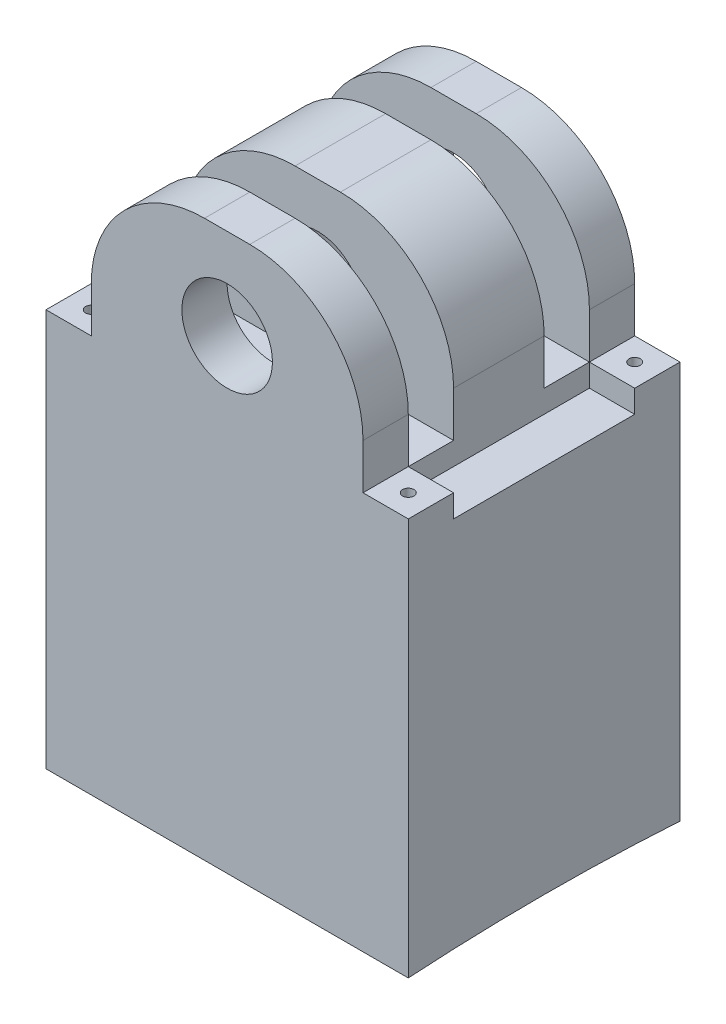
from build123d import *

# Parameters (mm, degrees)
SKETCH1_R                   = 25.4
BOSS_EXTRUDE1_DEPTH         = 152.4
SKETCH3_W                   = 25.4
SKETCH3_H                   = 88.9
CUT_EXTRUDE1_DEPTH          = 102.6
CUT_EXTRUDE1_DEPTH_BACK     = 102.6
F_1_4_0_25_DIAMETER_HOLE1_D = 6.35
SKETCH4_W                   = 25.4
SKETCH4_H                   = 101.6
CUT_EXTRUDE2_DEPTH          = 13.7
SKETCH7_W                   = 203.2
SKETCH7_H                   = 210.309489201
BOSS_EXTRUDE2_DEPTH         = 152.4
CUT_EXTRUDE3_DEPTH          = 204.2


with BuildPart() as part:
    # Sketch1 → Boss-Extrude1 (new body)
    with BuildSketch(Plane.XY):
        with BuildLine():
            Line((-101.6, -50.8), (101.6, -50.8))
            Line((101.6, -50.8), (101.6, -38.1))
            Line((101.6, -38.1), (76.2, -38.1))
            Line((76.2, -38.1), (76.2, -12.7))
            ThreePointArc((76.2, -12.7), (57.601280605, 32.201280605), (12.7, 50.8))
            Line((12.7, 50.8), (-12.7, 50.8))
            ThreePointArc((-12.7, 50.8), (-57.601280605, 32.201280605), (-76.2, -12.7))
            Line((-76.2, -12.7), (-76.2, -38.1))
            Line((-76.2, -38.1), (-101.6, -38.1))
            Line((-101.6, -38.1), (-101.6, -50.8))
        make_face()
        Circle(SKETCH1_R, mode=Mode.SUBTRACT)
    extrude(amount=BOSS_EXTRUDE1_DEPTH)

    # Sketch3 → Cut-Extrude1 (cut, two sides)
    with BuildSketch(Plane(origin=(0, 0, 0), x_dir=(0, 0, -1), z_dir=(1, 0, 0))) as cut_extrude1_sk:
        with Locations((-114.3, 6.35)):
            Rectangle(SKETCH3_W, SKETCH3_H)
        with Locations((-38.1, 6.35)):
            Rectangle(SKETCH3_W, SKETCH3_H)
    extrude(amount=CUT_EXTRUDE1_DEPTH, mode=Mode.SUBTRACT)
    extrude(cut_extrude1_sk.sketch, amount=-CUT_EXTRUDE1_DEPTH_BACK, mode=Mode.SUBTRACT)

    # 1/4 (0.25) Diameter Hole1 (through all)
    with Locations(Plane(origin=(0, -38.1, 0), x_dir=(1, 0, 0), z_dir=(0, 1, 0))):
        with Locations((-88.9, -12.7), (-88.9, -139.7), (88.9, -12.7), (88.9, -139.7)):
            Hole(F_1_4_0_25_DIAMETER_HOLE1_D / 2)

    # Sketch4 → Cut-Extrude2 (cut, through all)
    with BuildSketch(Plane(origin=(0, -38.1, 0), x_dir=(1, 0, 0), z_dir=(0, 1, 0))):
        with Locations((-88.9, -76.2)):
            Rectangle(SKETCH4_W, SKETCH4_H)
        with Locations((88.9, -76.2)):
            Rectangle(SKETCH4_W, SKETCH4_H)
    extrude(amount=-CUT_EXTRUDE2_DEPTH, mode=Mode.SUBTRACT)

    # Sketch7 → Boss-Extrude2 (add)
    with BuildSketch(Plane(origin=(0, 0, 0), x_dir=(-1, 0, 0), z_dir=(0, 0, -1))):
        with Locations((0, -155.954744601)):
            Rectangle(SKETCH7_W, SKETCH7_H)
    extrude(amount=-BOSS_EXTRUDE2_DEPTH)

    # Sketch8 → Cut-Extrude3 (cut, through all)
    with BuildSketch(Plane(origin=(101.6, 0, 0), x_dir=(0, 0, -1), z_dir=(1, 0, 0))):
        with BuildLine():
            Line((-152.4, -261.109489201), (0, -261.109489201))
            ThreePointArc((0, -261.109489201), (-76.2, -258.687695415), (-152.4, -261.109489201))
        make_face()
    extrude(amount=-CUT_EXTRUDE3_DEPTH, mode=Mode.SUBTRACT)


solid = part.part
